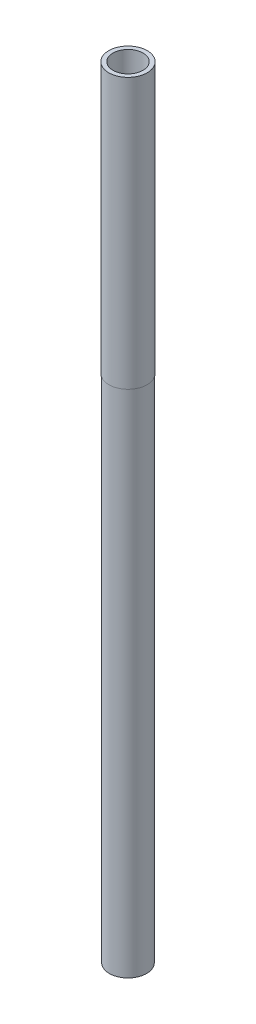
from build123d import *

# Parameters (mm, degrees)
SKETCH1_R           = 0.31
SKETCH1_R_2         = 0.25
BOSS_EXTRUDE1_DEPTH = 13
SKETCH2_R           = 0.32
SKETCH2_R_2         = 0.31
BOSS_EXTRUDE2_DEPTH = 4.5


with BuildPart() as part:
    # Sketch1 → Boss-Extrude1 (new body)
    with BuildSketch(Plane(origin=(0, 0, 0), x_dir=(1, 0, 0), z_dir=(0, 1, 0))):
        Circle(SKETCH1_R)
        Circle(SKETCH1_R_2, mode=Mode.SUBTRACT)
    extrude(amount=BOSS_EXTRUDE1_DEPTH)

    # Sketch2 → Boss-Extrude2 (add)
    with BuildSketch(Plane(origin=(0, 13, 0), x_dir=(1, 0, 0), z_dir=(0, 1, 0))):
        Circle(SKETCH2_R)
        Circle(SKETCH2_R_2, mode=Mode.SUBTRACT)
    extrude(amount=-BOSS_EXTRUDE2_DEPTH)


solid = part.part
